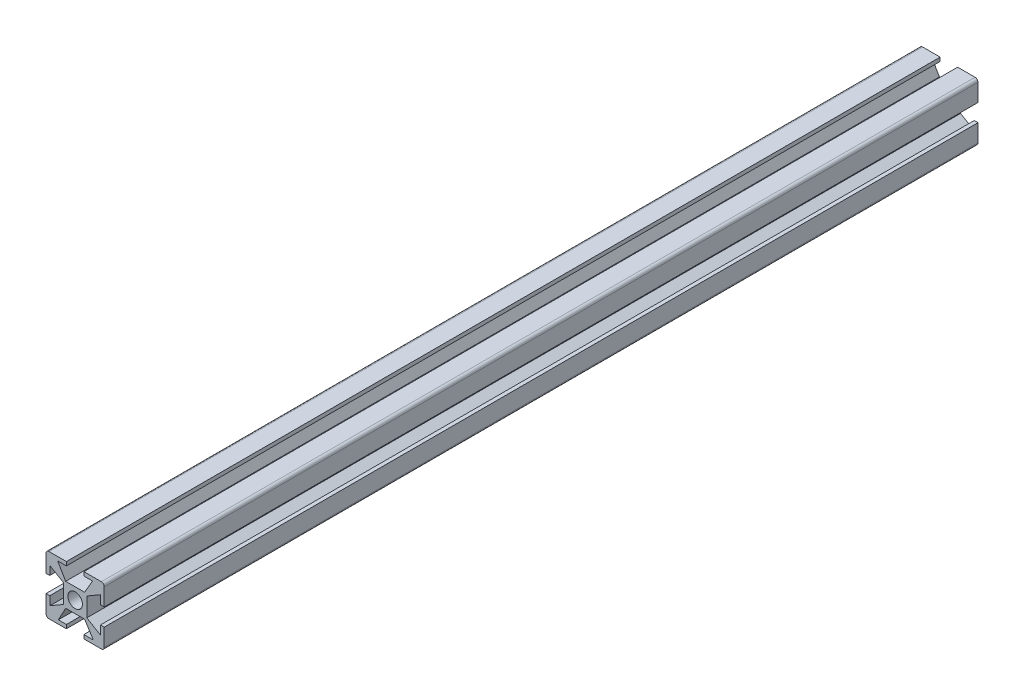
from build123d import *

# Parameters (mm, degrees)
CROQUIS1_W              = 8
CROQUIS1_H              = 8
CROQUIS1_R              = 2.5
SALIENTE_EXTRUIR4_DEPTH = 300


with BuildPart() as part:
    # Croquis1 → Saliente-Extruir4 (new body)
    with BuildSketch(Plane.XY):
        with BuildLine():
            Line((-3, 8.7), (-3, 10))
            Line((-3, 10), (-9, 10))
            ThreePointArc((-9, 10), (-9.707106781, 9.707106781), (-10, 9))
            Line((-10, 9), (-10, 3))
            Line((-10, 3), (-8.7, 3))
            Line((-8.7, 3), (-8.7, 6))
            Line((-8.7, 6), (-4, 3.25))
            Line((-4, 3.25), (-4, 4))
            Line((-4, 4), (-3.25, 4))
            Line((-3.25, 4), (-6, 8.7))
            Line((-6, 8.7), (-3, 8.7))
        make_face()
        with BuildLine():
            Line((9, 10), (3, 10))
            Line((3, 10), (3, 8.7))
            Line((3, 8.7), (6, 8.7))
            Line((6, 8.7), (3.25, 4))
            Line((3.25, 4), (4, 4))
            Line((4, 4), (4, 3.25))
            Line((4, 3.25), (8.7, 6))
            Line((8.7, 6), (8.7, 3))
            Line((8.7, 3), (10, 3))
            Line((10, 3), (10, 9))
            ThreePointArc((10, 9), (9.707106781, 9.707106781), (9, 10))
        make_face()
        with BuildLine():
            Line((10, -9), (10, -3))
            Line((10, -3), (8.7, -3))
            Line((8.7, -3), (8.7, -6))
            Line((8.7, -6), (4, -3.25))
            Line((4, -3.25), (4, -4))
            Line((4, -4), (3.25, -4))
            Line((3.25, -4), (6.25, -8.7))
            Line((6.25, -8.7), (3, -8.7))
            Line((3, -8.7), (3, -10))
            Line((3, -10), (9, -10))
            ThreePointArc((9, -10), (9.707106781, -9.707106781), (10, -9))
        make_face()
        with BuildLine():
            Line((-8.7, -3), (-10, -3))
            Line((-10, -3), (-10, -9))
            ThreePointArc((-10, -9), (-9.707106781, -9.707106781), (-9, -10))
            Line((-9, -10), (-3, -10))
            Line((-3, -10), (-3, -8.7))
            Line((-3, -8.7), (-5.75, -8.7))
            Line((-5.75, -8.7), (-3.25, -4))
            Line((-3.25, -4), (-4, -4))
            Line((-4, -4), (-4, -3.25))
            Line((-4, -3.25), (-8.7, -6))
            Line((-8.7, -6), (-8.7, -3))
        make_face()
        Rectangle(CROQUIS1_W, CROQUIS1_H)
        Circle(CROQUIS1_R, mode=Mode.SUBTRACT)
    extrude(amount=SALIENTE_EXTRUIR4_DEPTH)


solid = part.part
